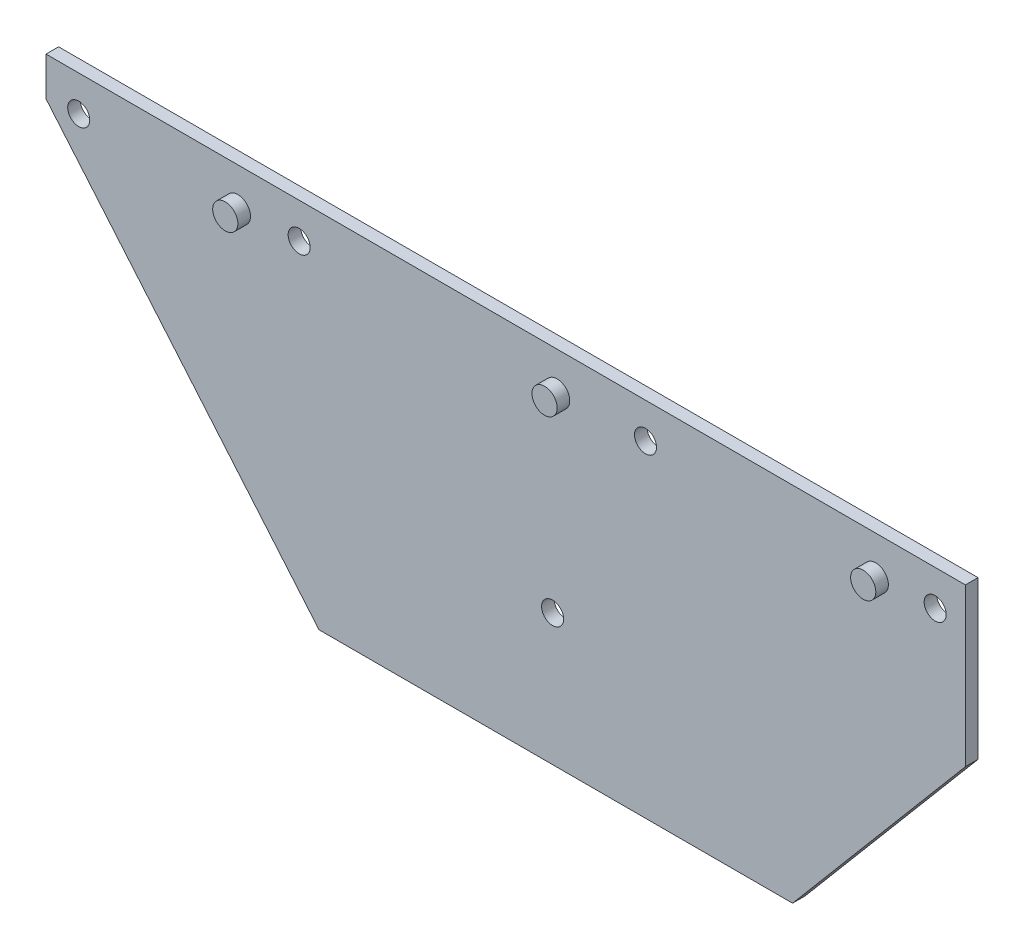
from build123d import *

# Parameters (mm, degrees)
RESSALTO_EXTRUS_O1_DEPTH = 2
CORTE_EXTRUS_O1_REACH    = 4
ESBO_O2_R                = 1.75
ESBO_O3_R                = 2
RESSALTO_EXTRUS_O2_DEPTH = 2


with BuildPart() as part:
    # Esboço1 → Ressalto-extrusão1 (new body)
    with BuildSketch(Plane.XY):
        Polygon((-73, 22.58983114), (-29.645188864, -28.75), (45.554811136, -28.75), (73, 3.75), (73, 28.75), (-73, 28.75), align=None)
    extrude(amount=RESSALTO_EXTRUS_O1_DEPTH)

    # Esboço2 → Corte-extrusão1 (cut, up to next)
    with BuildSketch(Plane.XY.offset(2), mode=Mode.PRIVATE) as corte_extrus_o1_sk1:
        with Locations((22.2, 23.13)):
            Circle(ESBO_O2_R)
    corte_extrus_o1_tool1 = extrude(corte_extrus_o1_sk1.sketch, amount=-CORTE_EXTRUS_O1_REACH, mode=Mode.PRIVATE) & part.part
    add(corte_extrus_o1_tool1.solids().sort_by_distance((22.2, 23.13, 2))[0], mode=Mode.SUBTRACT)
    # Esboço2 → Corte-extrusão1 (cut, up to next)
    with BuildSketch(Plane.XY.offset(2), mode=Mode.PRIVATE) as corte_extrus_o1_sk2:
        with Locations((68.2, 23.13)):
            Circle(ESBO_O2_R)
    corte_extrus_o1_tool2 = extrude(corte_extrus_o1_sk2.sketch, amount=-CORTE_EXTRUS_O1_REACH, mode=Mode.PRIVATE) & part.part
    add(corte_extrus_o1_tool2.solids().sort_by_distance((68.2, 23.13, 2))[0], mode=Mode.SUBTRACT)
    # Esboço2 → Corte-extrusão1 (cut, up to next)
    with BuildSketch(Plane.XY.offset(2), mode=Mode.PRIVATE) as corte_extrus_o1_sk3:
        with Locations((-32.8, 23.13)):
            Circle(ESBO_O2_R)
    corte_extrus_o1_tool3 = extrude(corte_extrus_o1_sk3.sketch, amount=-CORTE_EXTRUS_O1_REACH, mode=Mode.PRIVATE) & part.part
    add(corte_extrus_o1_tool3.solids().sort_by_distance((-32.8, 23.13, 2))[0], mode=Mode.SUBTRACT)
    # Esboço2 → Corte-extrusão1 (cut, up to next)
    with BuildSketch(Plane.XY.offset(2), mode=Mode.PRIVATE) as corte_extrus_o1_sk4:
        with Locations((-67.8, 23.13)):
            Circle(ESBO_O2_R)
    corte_extrus_o1_tool4 = extrude(corte_extrus_o1_sk4.sketch, amount=-CORTE_EXTRUS_O1_REACH, mode=Mode.PRIVATE) & part.part
    add(corte_extrus_o1_tool4.solids().sort_by_distance((-67.8, 23.13, 2))[0], mode=Mode.SUBTRACT)
    # Esboço2 → Corte-extrusão1 (cut, up to next)
    with BuildSketch(Plane.XY.offset(2), mode=Mode.PRIVATE) as corte_extrus_o1_sk5:
        with Locations((7.45, -7.87)):
            Circle(ESBO_O2_R)
    corte_extrus_o1_tool5 = extrude(corte_extrus_o1_sk5.sketch, amount=-CORTE_EXTRUS_O1_REACH, mode=Mode.PRIVATE) & part.part
    add(corte_extrus_o1_tool5.solids().sort_by_distance((7.45, -7.87, 2))[0], mode=Mode.SUBTRACT)

    # Esboço3 → Ressalto-extrusão2 (add)
    with BuildSketch(Plane.XY.offset(2)):
        with Locations((8.17, 22.662028239)):
            Circle(ESBO_O3_R)
        with Locations((58.77, 22.662028239)):
            Circle(ESBO_O3_R)
        with Locations((-42.53, 22.662028239)):
            Circle(ESBO_O3_R)
    extrude(amount=RESSALTO_EXTRUS_O2_DEPTH)


solid = part.part
